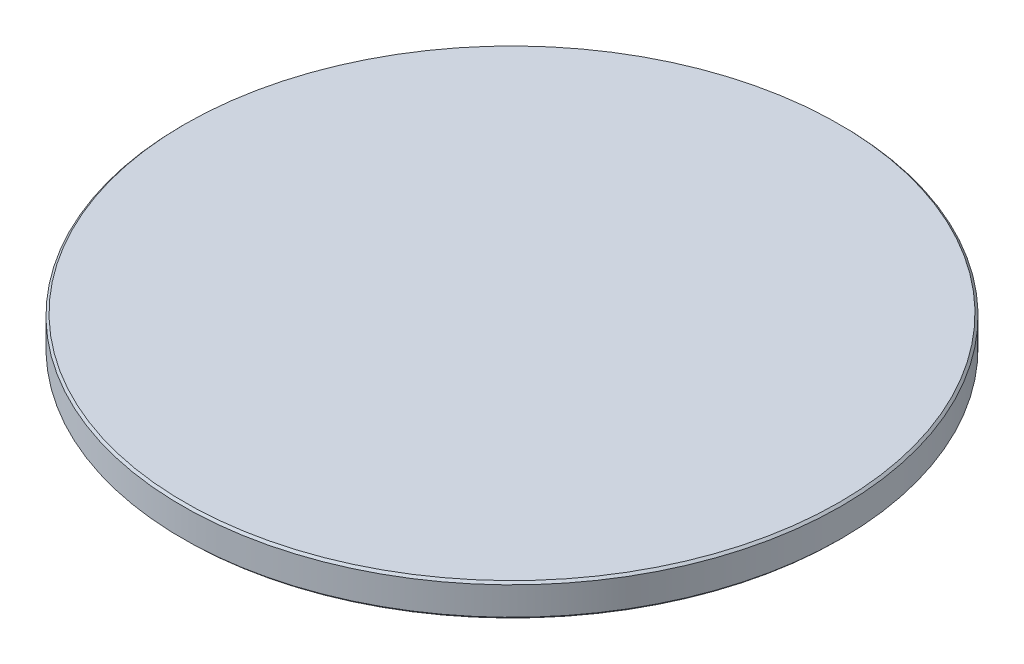
from build123d import *


with BuildPart() as part:
    # Schizzo1 → Rivoluzione1 (revolve)
    with BuildSketch(Plane.XY):
        Polygon((0, 3), (0, 0), (-30.3, 0), (-30.5, 0.2), (-30.5, 2.8), (-30.3, 3), align=None)
    revolve(axis=Axis((0, 3, 0), (0, -1, 0)))


solid = part.part
